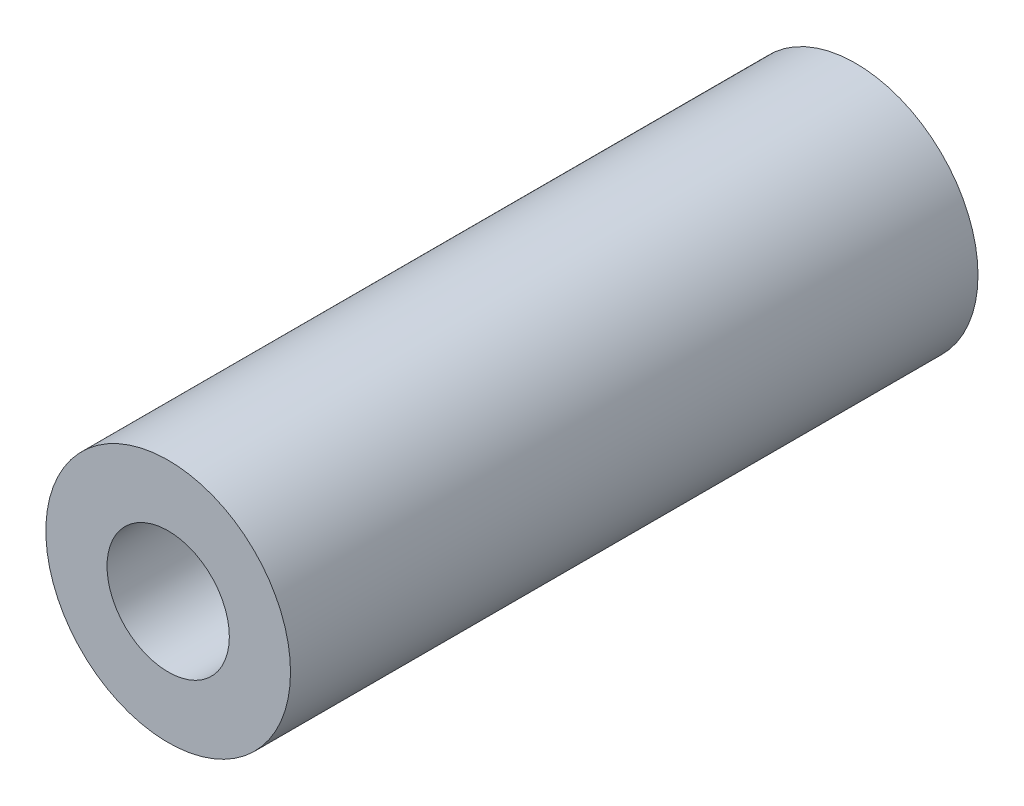
from build123d import *

# Parameters (mm, degrees)
SKETCH1_R           = 12.7
SKETCH1_R_2         = 6.35
BOSS_EXTRUDE1_DEPTH = 71.374


with BuildPart() as part:
    # Sketch1 → Boss-Extrude1 (new body)
    with BuildSketch(Plane.XY):
        Circle(SKETCH1_R)
        Circle(SKETCH1_R_2, mode=Mode.SUBTRACT)
    extrude(amount=BOSS_EXTRUDE1_DEPTH)


solid = part.part
